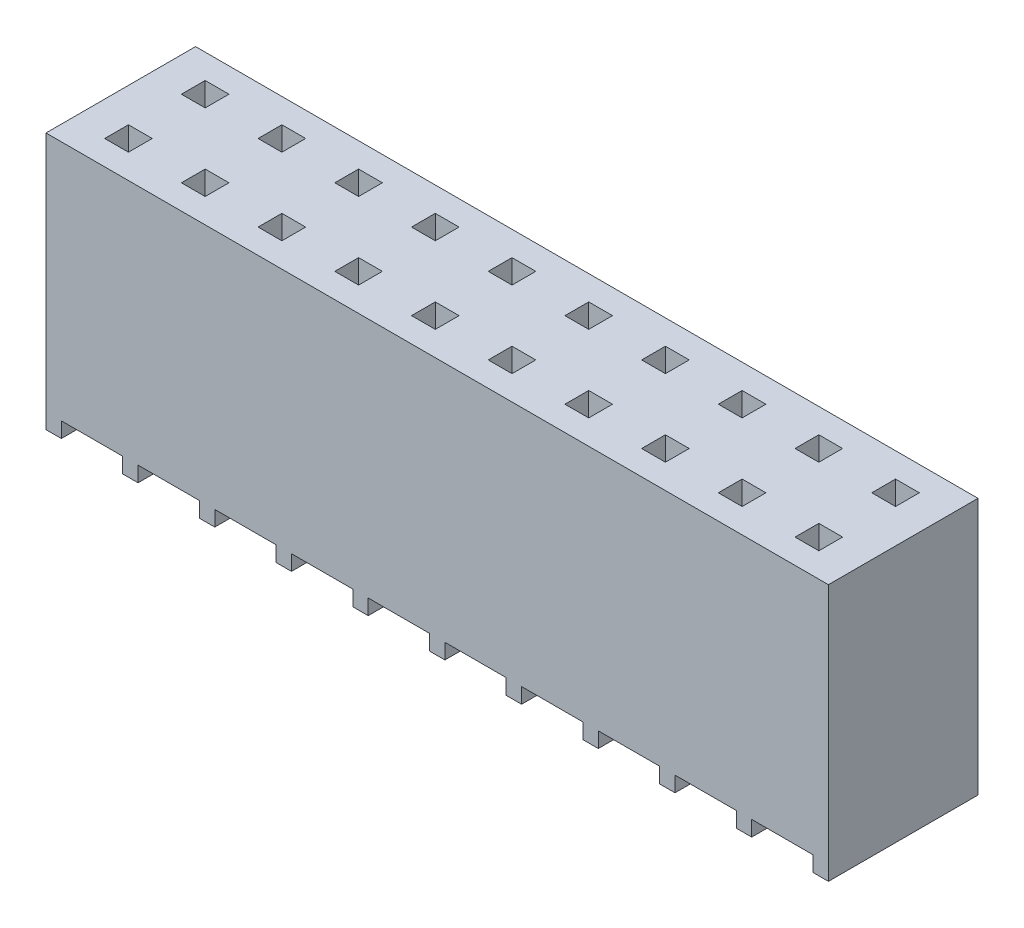
from build123d import *

# Parameters (mm, degrees)
SKETCH1_W            = 25.908
SKETCH1_H            = 8.001
BOSS_EXTRUDE1_DEPTH  = 4.953
SKETCH2_W            = 0.7874
SKETCH2_H            = 0.7874
CUT_EXTRUDE1_DEPTH   = 16.425795579
LPATTERN1_COUNT      = 2
LPATTERN1_PITCH      = 2.54
LPATTERN1_COUNT_DIR2 = 10
LPATTERN1_PITCH_DIR2 = 2.54
SKETCH3_W            = 0.508
SKETCH3_H            = 4.953
BOSS_EXTRUDE2_DEPTH  = 0.508
LPATTERN2_COUNT      = 11
LPATTERN2_PITCH      = 2.54


with BuildPart() as part:
    # Sketch1 → Boss-Extrude1 (new body)
    with BuildSketch(Plane.XY.offset(2.4765)):
        with Locations((0, 4.5085)):
            Rectangle(SKETCH1_W, SKETCH1_H)
    extrude(amount=-BOSS_EXTRUDE1_DEPTH)

    # Sketch2 → Cut-Extrude1 (cut, through all)
    with BuildSketch(Plane.XZ.offset(-0.508)):
        with Locations((11.43, -1.27)):
            Rectangle(SKETCH2_W, SKETCH2_H)
    cut_extrude1 = extrude(amount=-CUT_EXTRUDE1_DEPTH, mode=Mode.SUBTRACT)

    # LPattern1: Cut-Extrude1 2 × 10
    with Locations(*[(-j * LPATTERN1_PITCH_DIR2, 0, i * LPATTERN1_PITCH) for i in range(LPATTERN1_COUNT) for j in range(LPATTERN1_COUNT_DIR2) if (i, j) != (0, 0)]):
        add(cut_extrude1, mode=Mode.SUBTRACT)

    # Sketch3 → Boss-Extrude2 (add)
    with BuildSketch(Plane.XZ.offset(-0.508)):
        with Locations((-12.7, 0)):
            Rectangle(SKETCH3_W, SKETCH3_H)
    boss_extrude2 = extrude(amount=BOSS_EXTRUDE2_DEPTH)

    # LPattern2: Boss-Extrude2 ×11
    with Locations(*[(i * LPATTERN2_PITCH, 0, 0) for i in range(1, LPATTERN2_COUNT)]):
        add(boss_extrude2)


solid = part.part
